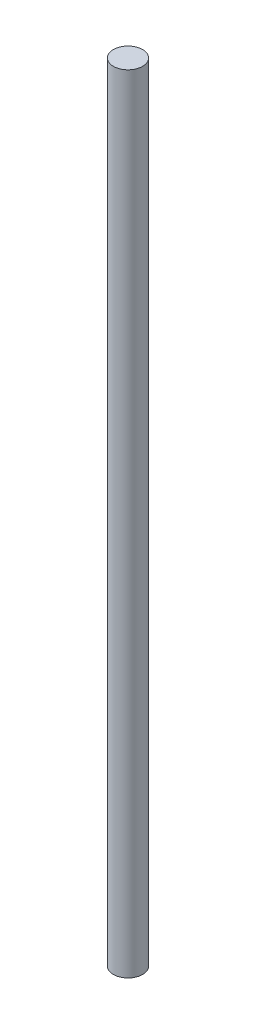
from build123d import *

# Parameters (mm, degrees)
SKETCH1_R           = 914.4
BOSS_EXTRUDE1_DEPTH = 49276


with BuildPart() as part:
    # Sketch1 → Boss-Extrude1 (new body)
    with BuildSketch(Plane(origin=(0, 0, 0), x_dir=(1, 0, 0), z_dir=(0, 1, 0))):
        Circle(SKETCH1_R)
    extrude(amount=BOSS_EXTRUDE1_DEPTH)


solid = part.part
